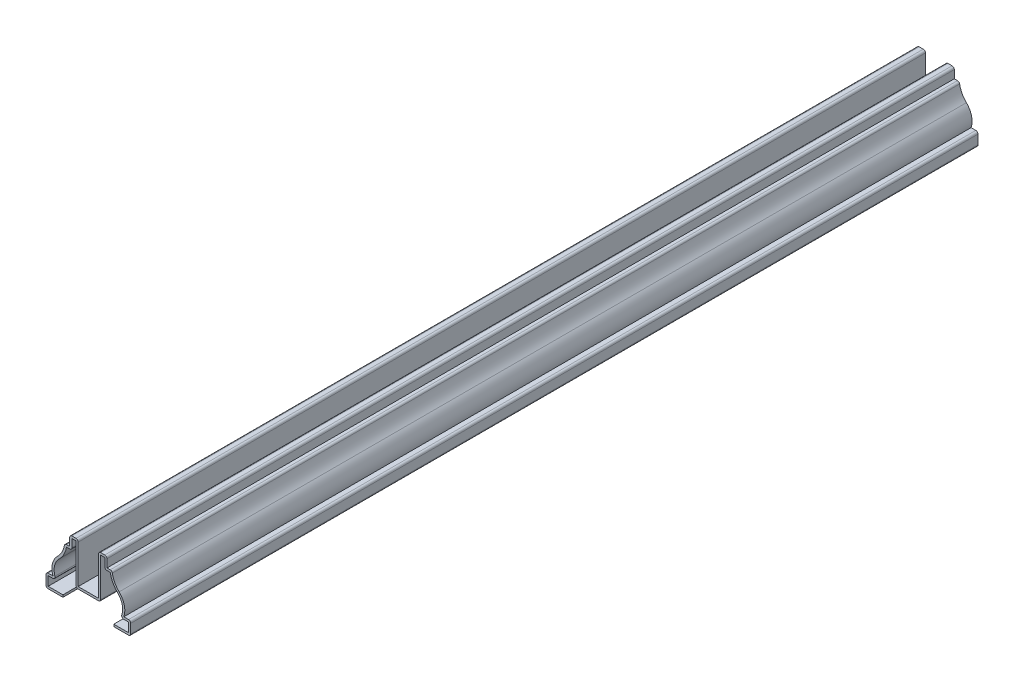
from build123d import *

# Parameters (mm, degrees)
EXTRUDE_THIN1_DEPTH = 396.875
FILLET1_R           = 1.016


with BuildPart() as part:
    # Sketch1 → Extrude-Thin1 (new body)
    with BuildSketch(Plane.XY):
        with BuildLine():
            Line((-11.90625, 0), (-19.84375, 0))
            Line((-19.84375, 0), (-19.84375, 6.35))
            Line((-19.84375, 6.35), (-16.611859403, 6.35))
            ThreePointArc((-16.611859403, 6.35), (-16.819864191, 11.185113028), (-14.420873366, 15.388257922))
            ThreePointArc((-14.420873366, 15.388257922), (-12.164462393, 18.51520612), (-11.1125, 22.225))
            Line((-11.1125, 22.225), (-8.73125, 22.225))
            Line((-8.73125, 22.225), (-8.73125, 26.9875))
            Line((-8.73125, 26.9875), (-4.7625, 26.9875))
            Line((-4.7625, 26.9875), (-4.7625, 7.9375))
            Line((-4.7625, 7.9375), (4.7625, 7.9375))
            Line((4.7625, 7.9375), (4.7625, 26.9875))
            Line((4.7625, 26.9875), (8.73125, 26.9875))
            Line((8.73125, 26.9875), (8.73125, 22.225))
            Line((8.73125, 22.225), (11.1125, 22.225))
            ThreePointArc((11.1125, 22.225), (12.164462393, 18.51520612), (14.420873366, 15.388257922))
            ThreePointArc((14.420873366, 15.388257922), (16.819864191, 11.185113028), (16.611859403, 6.35))
            Line((16.611859403, 6.35), (19.84375, 6.35))
            Line((19.84375, 6.35), (19.84375, 0))
            Line((19.84375, 0), (11.90625, 0))
            Line((11.90625, 0), (11.90625, 1.016))
            Line((11.90625, 1.016), (18.82775, 1.016))
            Line((18.82775, 1.016), (18.82775, 5.334))
            Line((18.82775, 5.334), (15.052239099, 5.334))
            ThreePointArc((15.052239099, 5.334), (15.971237356, 10.225128152), (13.712626283, 14.659806091))
            ThreePointArc((13.712626283, 14.659806091), (11.458524166, 17.661660911), (10.230316486, 21.209))
            Line((10.230316486, 21.209), (7.71525, 21.209))
            Line((7.71525, 21.209), (7.71525, 25.9715))
            Line((7.71525, 25.9715), (5.7785, 25.9715))
            Line((5.7785, 25.9715), (5.7785, 6.9215))
            Line((5.7785, 6.9215), (-5.7785, 6.9215))
            Line((-5.7785, 6.9215), (-5.7785, 25.9715))
            Line((-5.7785, 25.9715), (-7.71525, 25.9715))
            Line((-7.71525, 25.9715), (-7.71525, 21.209))
            Line((-7.71525, 21.209), (-10.230316486, 21.209))
            ThreePointArc((-10.230316486, 21.209), (-11.458524166, 17.661660911), (-13.712626283, 14.659806091))
            ThreePointArc((-13.712626283, 14.659806091), (-15.971237356, 10.225128152), (-15.052239099, 5.334))
            Line((-15.052239099, 5.334), (-18.82775, 5.334))
            Line((-18.82775, 5.334), (-18.82775, 1.016))
            Line((-18.82775, 1.016), (-11.90625, 1.016))
            Line((-11.90625, 1.016), (-11.90625, 0))
        make_face()
    extrude(amount=-EXTRUDE_THIN1_DEPTH)

    # Fillet1
    fillet1_edges = [part.edges().sort_by_distance(p)[0] for p in [
        (-19.84375, 0, -198.4375),
        (-19.84375, 6.35, -198.4375),
        (-11.1125, 22.225, -198.4375),
        (-8.73125, 26.9875, -198.4375),
        (-4.7625, 26.9875, -198.4375),
        (4.7625, 26.9875, -198.4375),
        (8.73125, 26.9875, -198.4375),
        (11.1125, 22.225, -198.4375),
        (19.84375, 6.35, -198.4375),
        (19.84375, 0, -198.4375),
        (15.052239099, 5.334, -198.4375),
        (7.71525, 21.209, -198.4375),
        (5.7785, 6.9215, -198.4375),
        (-5.7785, 6.9215, -198.4375),
        (-7.71525, 21.209, -198.4375),
        (-15.052239099, 5.334, -198.4375),
    ]]
    fillet(fillet1_edges, radius=FILLET1_R)


solid = part.part
